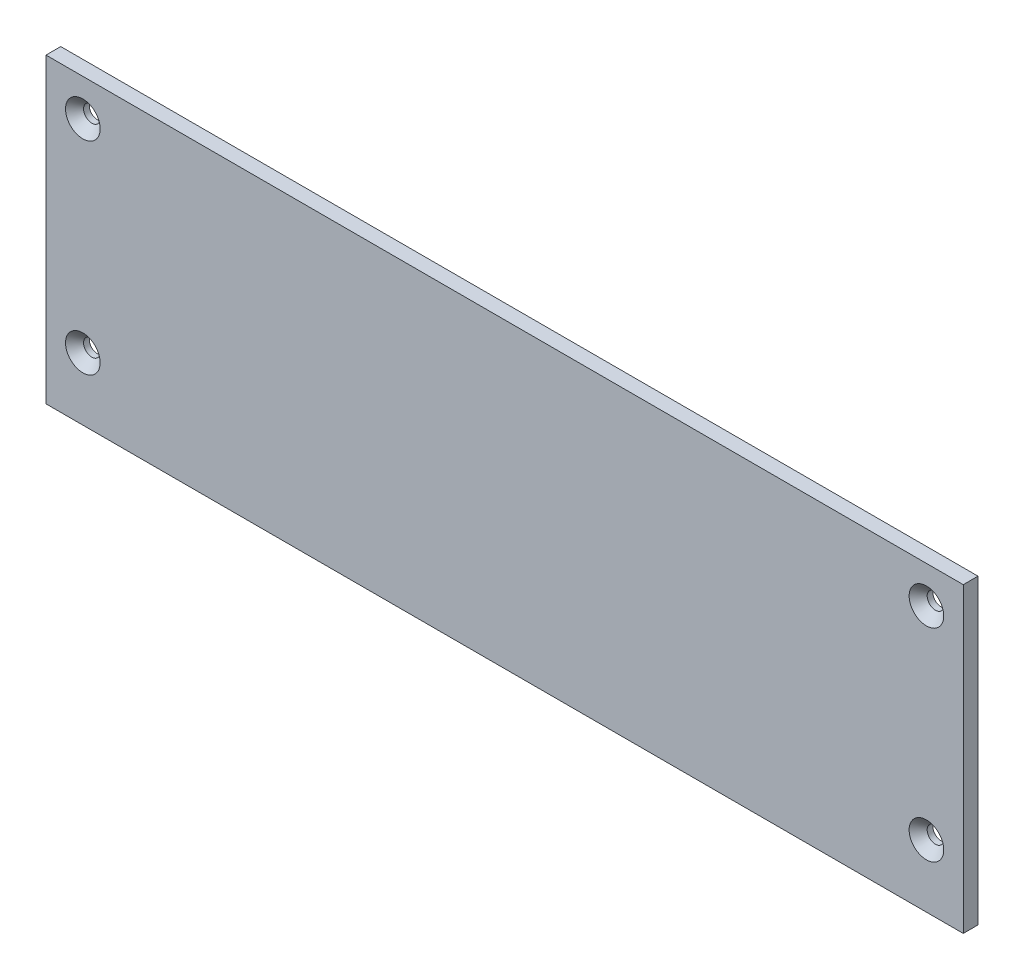
from build123d import *

# Parameters (mm, degrees)
ESQUISSE1_W                                 = 249
ESQUISSE1_H                                 = 82
BOSS_EXTRU_1_DEPTH                          = 4
FRAISAGE_POUR_VIS_T_TE_FRAIS_E_M42_AT_COUNT = 2
FRAISAGE_POUR_VIS_T_TE_FRAIS_E_M42_AT_PITCH = 55
FRAISAGE_POUR_VIS_T_TE_FRAIS_E_M42_2_COUNT  = 2
FRAISAGE_POUR_VIS_T_TE_FRAIS_E_M42_2_PITCH  = 229
FRAISAGE_POUR_VIS_T_TE_FRAIS_E_M42_3_COUNT  = 2
FRAISAGE_POUR_VIS_T_TE_FRAIS_E_M42_3_PITCH  = 235.512207752


with BuildPart() as part:
    # Esquisse1 → Boss.-Extru.1 (new body)
    with BuildSketch(Plane.XY):
        Rectangle(ESQUISSE1_W, ESQUISSE1_H)
    extrude(amount=BOSS_EXTRU_1_DEPTH)

    # Esquisse6 → Fraisage pour vis à tête fraisée M42 (revolve, cut)
    with BuildSketch(Plane(origin=(-114.5, -24, 4), x_dir=(0, -1, 0), z_dir=(1, 0, 0))):
        Polygon((0, 0), (0, 4), (2.25, 4), (2.25, 2.45), (4.7, 0), align=None)
    fraisage_pour_vis_t_te_frais_e_m42 = revolve(axis=Axis((-114.5, -24, 10.35), (0, 0, -1)), mode=Mode.SUBTRACT)

    # Fraisage pour vis à tête fraisée M42 at: Fraisage pour vis à tête fraisée M42 ×2
    with Locations(*[(0, i * FRAISAGE_POUR_VIS_T_TE_FRAIS_E_M42_AT_PITCH, 0) for i in range(1, FRAISAGE_POUR_VIS_T_TE_FRAIS_E_M42_AT_COUNT)]):
        add(fraisage_pour_vis_t_te_frais_e_m42, mode=Mode.SUBTRACT)

    # Fraisage pour vis _ t_te frais_e M42 2: Fraisage pour vis à tête fraisée M42 ×2
    with Locations(*[(i * FRAISAGE_POUR_VIS_T_TE_FRAIS_E_M42_2_PITCH, 0, 0) for i in range(1, FRAISAGE_POUR_VIS_T_TE_FRAIS_E_M42_2_COUNT)]):
        add(fraisage_pour_vis_t_te_frais_e_m42, mode=Mode.SUBTRACT)

    # Fraisage pour vis _ t_te frais_e M42 3: Fraisage pour vis à tête fraisée M42 ×2
    with Locations(*[Vector(0.972348747, 0.233533542, 0) * (i * FRAISAGE_POUR_VIS_T_TE_FRAIS_E_M42_3_PITCH) for i in range(1, FRAISAGE_POUR_VIS_T_TE_FRAIS_E_M42_3_COUNT)]):
        add(fraisage_pour_vis_t_te_frais_e_m42, mode=Mode.SUBTRACT)


solid = part.part
